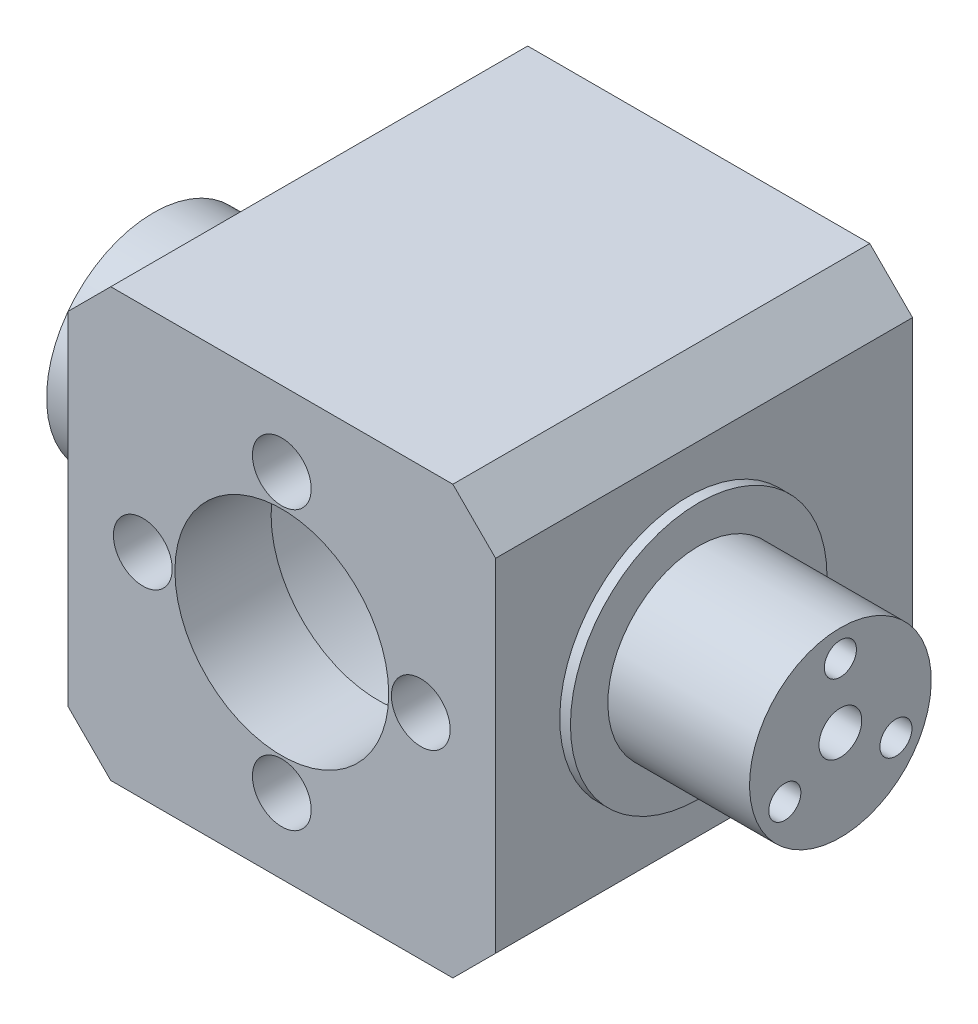
from build123d import *

# Parameters (mm, degrees)
ESQUISSE1_W             = 40
ESQUISSE1_H             = 40
ESQUISSE1_R             = 16
BOSS_EXTRU_1_DEPTH      = 30
ESQUISSE2_W             = 40
ESQUISSE2_H             = 40
BOSS_EXTRU_2_DEPTH      = 5
ESQUISSE3_R             = 1.5
ENL_V_MAT_EXTRU_1_DEPTH = 5
ESQUISSE4_R             = 10
ENL_V_MAT_EXTRU_2_DEPTH = 5
ESQUISSE5_R             = 10
BOSS_EXTRU_3_DEPTH      = 10
ESQUISSE6_R             = 12
BOSS_EXTRU_4_DEPTH      = 1
ESQUISSE7_R             = 8.5
BOSS_EXTRU_5_DEPTH      = 14.25
BOSS_EXTRU_6_START      = 1
ESQUISSE8_R             = 12
BOSS_EXTRU_6_DEPTH      = 1
BOSS_EXTRU_7_START      = 4
ESQUISSE9_W             = 40
ESQUISSE9_H             = 40
ESQUISSE9_R             = 2.75
ESQUISSE9_R_2           = 10
BOSS_EXTRU_7_DEPTH      = 4
ESQUISSE10_R            = 1.5
ESQUISSE10_R_2          = 2
ENL_V_MAT_EXTRU_3_DEPTH = 78.775719219
CHANFREIN1_SIZE         = 4


with BuildPart() as part:
    # Esquisse1 → Boss.-Extru.1 (new body)
    with BuildSketch(Plane.XY):
        Rectangle(ESQUISSE1_W, ESQUISSE1_H)
        Circle(ESQUISSE1_R, mode=Mode.SUBTRACT)
    extrude(amount=BOSS_EXTRU_1_DEPTH)

    # Esquisse2 → Boss.-Extru.2 (add)
    with BuildSketch(Plane.XY.offset(30)):
        Rectangle(ESQUISSE2_W, ESQUISSE2_H)
    extrude(amount=BOSS_EXTRU_2_DEPTH)

    # Esquisse3 → Enlèv. mat.-Extru.1 (cut)
    with BuildSketch(Plane.XY.offset(35)):
        with Locations((0, 13)):
            Circle(ESQUISSE3_R)
        with Locations((13, 0)):
            Circle(ESQUISSE3_R)
        with Locations((0, -13)):
            Circle(ESQUISSE3_R)
        with Locations((-13, 0)):
            Circle(ESQUISSE3_R)
    extrude(amount=-ENL_V_MAT_EXTRU_1_DEPTH, mode=Mode.SUBTRACT)

    # Esquisse4 → Enlèv. mat.-Extru.2 (cut)
    with BuildSketch(Plane.XY.offset(35)):
        Circle(ESQUISSE4_R)
    extrude(amount=-ENL_V_MAT_EXTRU_2_DEPTH, mode=Mode.SUBTRACT)

    # Esquisse5 → Boss.-Extru.3 (add)
    with BuildSketch(Plane.ZY.offset(20)):
        with Locations((21, 0)):
            Circle(ESQUISSE5_R)
    extrude(amount=BOSS_EXTRU_3_DEPTH)

    # Esquisse6 → Boss.-Extru.4 (add)
    with BuildSketch(Plane.ZY.offset(20)):
        with Locations((21, 0)):
            Circle(ESQUISSE6_R)
    extrude(amount=BOSS_EXTRU_4_DEPTH)

    # Esquisse7 → Boss.-Extru.5 (add)
    with BuildSketch(Plane(origin=(20, 0, 0), x_dir=(0, 0, -1), z_dir=(1, 0, 0))):
        with Locations((-21, 0)):
            Circle(ESQUISSE7_R)
    extrude(amount=BOSS_EXTRU_5_DEPTH)

    # Esquisse8 → Boss.-Extru.6 (add)
    with BuildSketch(Plane(origin=(20, 0, 0), x_dir=(0, 0, -1), z_dir=(1, 0, 0)).offset(BOSS_EXTRU_6_START)):
        with Locations((-21, 0)):
            Circle(ESQUISSE8_R)
    extrude(amount=-BOSS_EXTRU_6_DEPTH)

    # Esquisse9 → Boss.-Extru.7 (add)
    with BuildSketch(Plane.XY.offset(35).offset(BOSS_EXTRU_7_START)):
        Rectangle(ESQUISSE9_W, ESQUISSE9_H)
        with Locations((0, 13)):
            Circle(ESQUISSE9_R, mode=Mode.SUBTRACT)
        with Locations((-13, 0)):
            Circle(ESQUISSE9_R, mode=Mode.SUBTRACT)
        with Locations((0, -13)):
            Circle(ESQUISSE9_R, mode=Mode.SUBTRACT)
        with Locations((13, 0)):
            Circle(ESQUISSE9_R, mode=Mode.SUBTRACT)
        Circle(ESQUISSE9_R_2, mode=Mode.SUBTRACT)
    extrude(amount=-BOSS_EXTRU_7_DEPTH)

    # Esquisse10 → Enlèv. mat.-Extru.3 (cut, through all)
    with BuildSketch(Plane(origin=(34.25, 0, 0), x_dir=(0, 0, -1), z_dir=(1, 0, 0))):
        with Locations((-21, 6)):
            Circle(ESQUISSE10_R)
        with Locations((-15.803847577, -3)):
            Circle(ESQUISSE10_R)
        with Locations((-26.196152423, -3)):
            Circle(ESQUISSE10_R)
        with Locations((-21, 0)):
            Circle(ESQUISSE10_R_2)
    extrude(amount=-ENL_V_MAT_EXTRU_3_DEPTH, mode=Mode.SUBTRACT)

    # Chanfrein1
    chanfrein1_edges = [part.edges().sort_by_distance(p)[0] for p in [
        (-20, -20, 19.5),
        (20, -20, 19.5),
        (20, 20, 19.5),
        (-20, 20, 19.5),
    ]]
    chamfer(chanfrein1_edges, length=CHANFREIN1_SIZE)


solid = part.part
